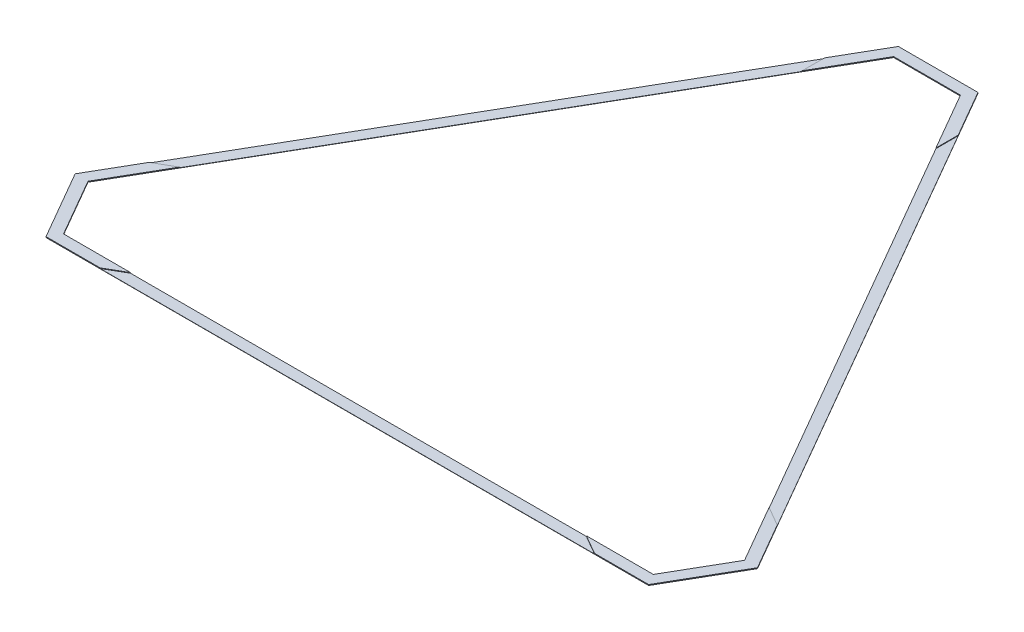
from build123d import *

# Parameters (mm, degrees)
BOSS_EXTRUDE1_DEPTH = 1.27
BOSS_EXTRUDE2_DEPTH = 2.65684


with BuildPart() as part:
    # Sketch1 → Boss-Extrude1 (new body)
    with BuildSketch(Plane(origin=(0, 0, 0), x_dir=(1, 0, 0), z_dir=(0, 1, 0))):
        Polygon((1557.25878735, -689.240751359), (181.729393675, 1693.246045791), (-181.729393675, 1693.246045791), (-1557.25878735, -689.240751359), (-1375.529393675, -1004.005294432), (1375.529393675, -1004.005294432), align=None)
        Polygon((152.4, 1642.446045791), (-152.4, 1642.446045791), (-1498.6, -689.240751359), (-1346.2, -953.205294432), (1346.2, -953.205294432), (1498.6, -689.240751359), align=None, mode=Mode.SUBTRACT)
    extrude(amount=BOSS_EXTRUDE1_DEPTH)

    # Sketch2 → Boss-Extrude2 (add)
    with BuildSketch(Plane(origin=(0, 1.27, 0), x_dir=(1, 0, 0), z_dir=(0, 1, 0))):
        Polygon((-181.729393675, 1693.246045791), (-305.308, 1479.201620907), (-305.308, 1377.601620907), (-152.4, 1642.446045791), (152.4, 1642.446045791), (305.308, 1377.601620907), (305.308, 1479.201620907), (181.729393675, 1693.246045791), align=None)
        Polygon((1557.25878735, -689.240751359), (1433.680181024, -475.196326475), (1345.692, -424.396326475), (1498.6, -689.240751359), (1346.2, -953.205294432), (1040.384, -953.205294432), (1128.372181024, -1004.005294432), (1375.529393675, -1004.005294432), align=None)
        Polygon((-1345.692, -424.396326475), (-1433.680181024, -475.196326475), (-1557.25878735, -689.240751359), (-1375.529393675, -1004.005294432), (-1128.372181024, -1004.005294432), (-1040.384, -953.205294432), (-1346.2, -953.205294432), (-1498.6, -689.240751359), align=None)
    extrude(amount=BOSS_EXTRUDE2_DEPTH)


solid = part.part
